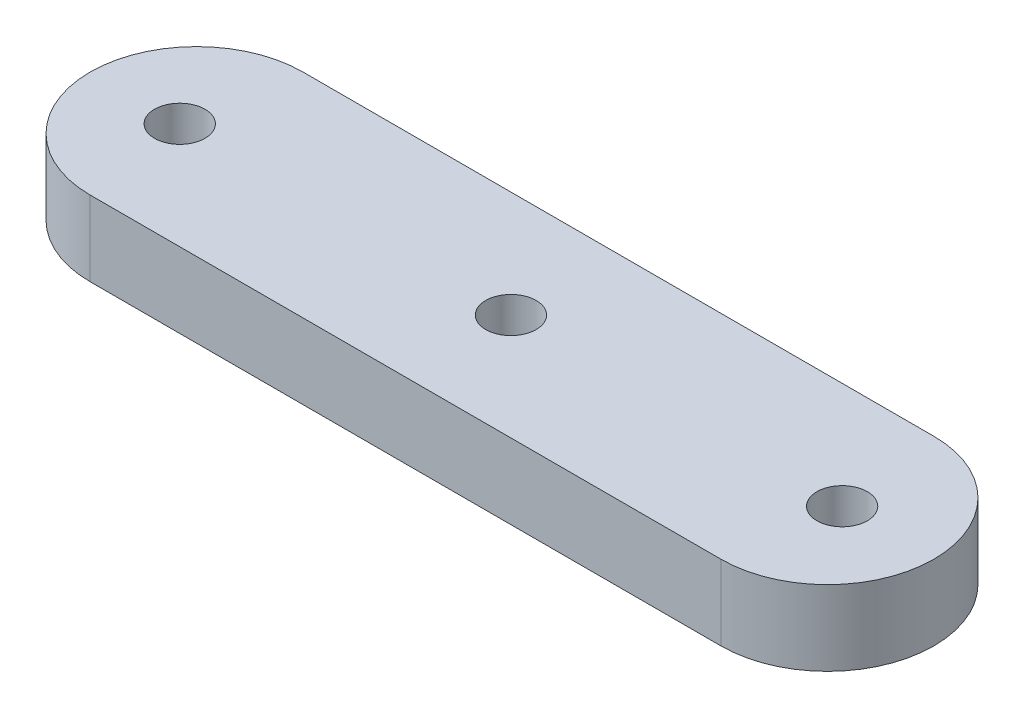
from build123d import *

# Parameters (mm, degrees)
BOSS_EXTRUDE1_DEPTH      = 4.763
M3_CLEARANCE_HOLE1_D     = 3.2
M3_CLEARANCE_HOLE1_DEPTH = 4.763


with BuildPart() as part:
    # Sketch1 → Boss-Extrude1 (new body)
    with BuildSketch(Plane(origin=(0, 0, 0), x_dir=(1, 0, 0), z_dir=(0, 1, 0))):
        with BuildLine():
            Line((-19.932225786, 6.750936854), (20.067774214, 6.750936854))
            ThreePointArc((20.067774214, 6.750936854), (26.818711069, 0), (20.067774214, -6.750936854))
            Line((20.067774214, -6.750936854), (-19.932225786, -6.750936854))
            ThreePointArc((-19.932225786, -6.750936854), (-26.68316264, 0), (-19.932225786, 6.750936854))
        make_face()
    extrude(amount=BOSS_EXTRUDE1_DEPTH)

    # M3 Clearance Hole1
    with Locations(Plane(origin=(0, 4.763, 0), x_dir=(1, 0, 0), z_dir=(0, 1, 0))):
        with Locations((-21, 0), (0, 0), (21, 0)):
            Hole(M3_CLEARANCE_HOLE1_D / 2, depth=M3_CLEARANCE_HOLE1_DEPTH)


solid = part.part
